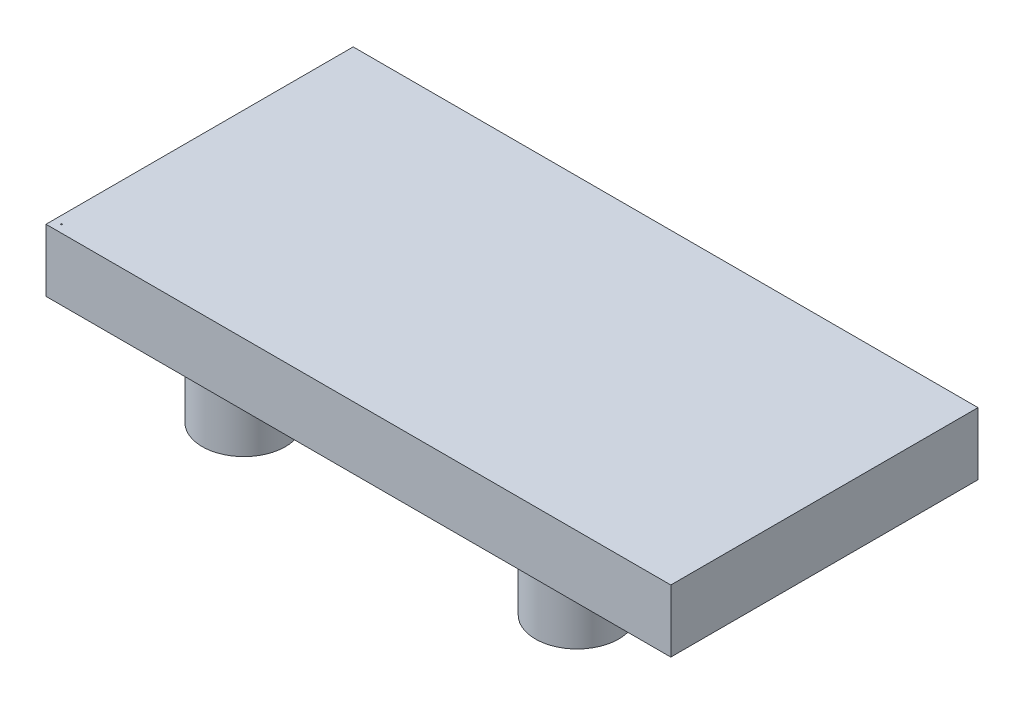
from build123d import *

# Parameters (mm, degrees)
SKETCH1_W           = 3048
SKETCH1_H           = 1498.6
BOSS_EXTRUDE1_DEPTH = 304.8
SKETCH2_R           = 203.2
BOSS_EXTRUDE2_DEPTH = 304.8
SKETCH3_R           = 3.175
CUT_EXTRUDE1_DEPTH  = 25.4


with BuildPart() as part:
    # Sketch1 → Boss-Extrude1 (new body)
    with BuildSketch(Plane(origin=(0, 0, 0), x_dir=(1, 0, 0), z_dir=(0, 1, 0))):
        with Locations((1524, 749.3)):
            Rectangle(SKETCH1_W, SKETCH1_H)
    extrude(amount=-BOSS_EXTRUDE1_DEPTH)

    # Sketch2 → Boss-Extrude2 (add)
    with BuildSketch(Plane.XZ.offset(304.8)):
        with Locations((711.2, -254)):
            Circle(SKETCH2_R)
        with Locations((2336.8, -254)):
            Circle(SKETCH2_R)
        with Locations((711.2, -1270)):
            Circle(SKETCH2_R)
        with Locations((2336.8, -1270)):
            Circle(SKETCH2_R)
    extrude(amount=BOSS_EXTRUDE2_DEPTH)

    # Sketch3 → Cut-Extrude1 (cut)
    with BuildSketch(Plane(origin=(0, 0, 0), x_dir=(1, 0, 0), z_dir=(0, 1, 0))):
        with Locations((38.1, 38.1)):
            Circle(SKETCH3_R)
    extrude(amount=-CUT_EXTRUDE1_DEPTH, mode=Mode.SUBTRACT)


solid = part.part
